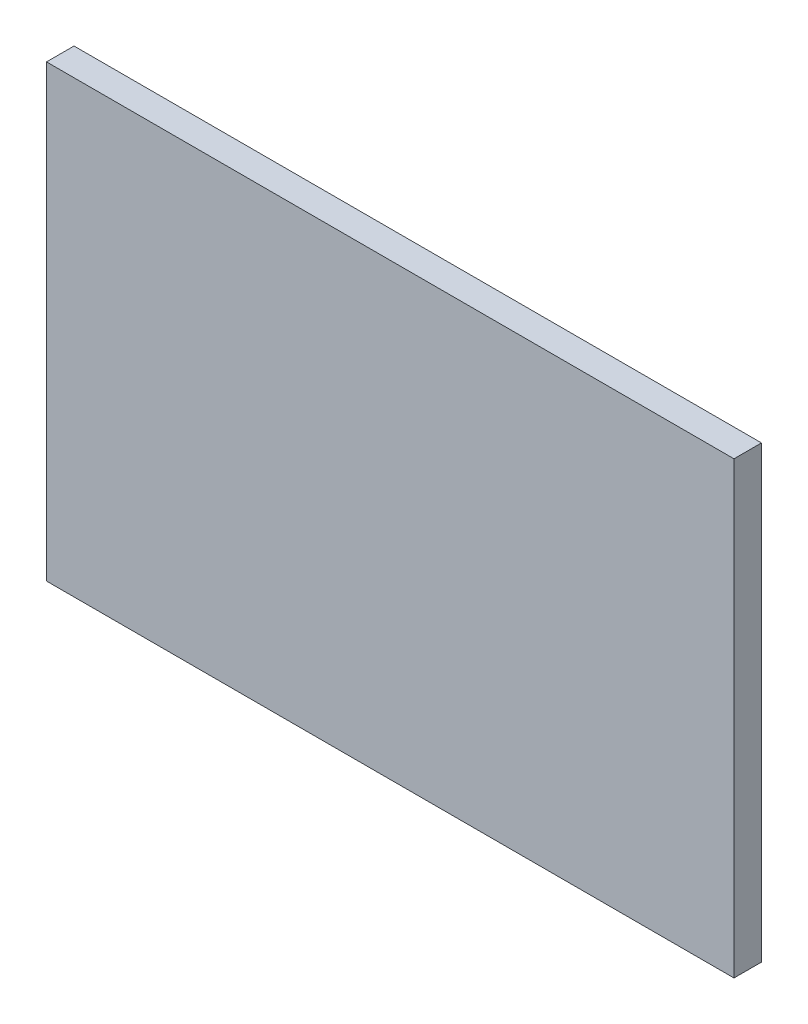
from build123d import *

# Parameters (mm, degrees)
ESQUISSE1_W        = 250
ESQUISSE1_H        = 163.521893492
BOSS_EXTRU_1_DEPTH = 10


with BuildPart() as part:
    # Esquisse1 → Boss.-Extru.1 (new body)
    with BuildSketch(Plane.XY):
        Rectangle(ESQUISSE1_W, ESQUISSE1_H)
    extrude(amount=BOSS_EXTRU_1_DEPTH)


solid = part.part
